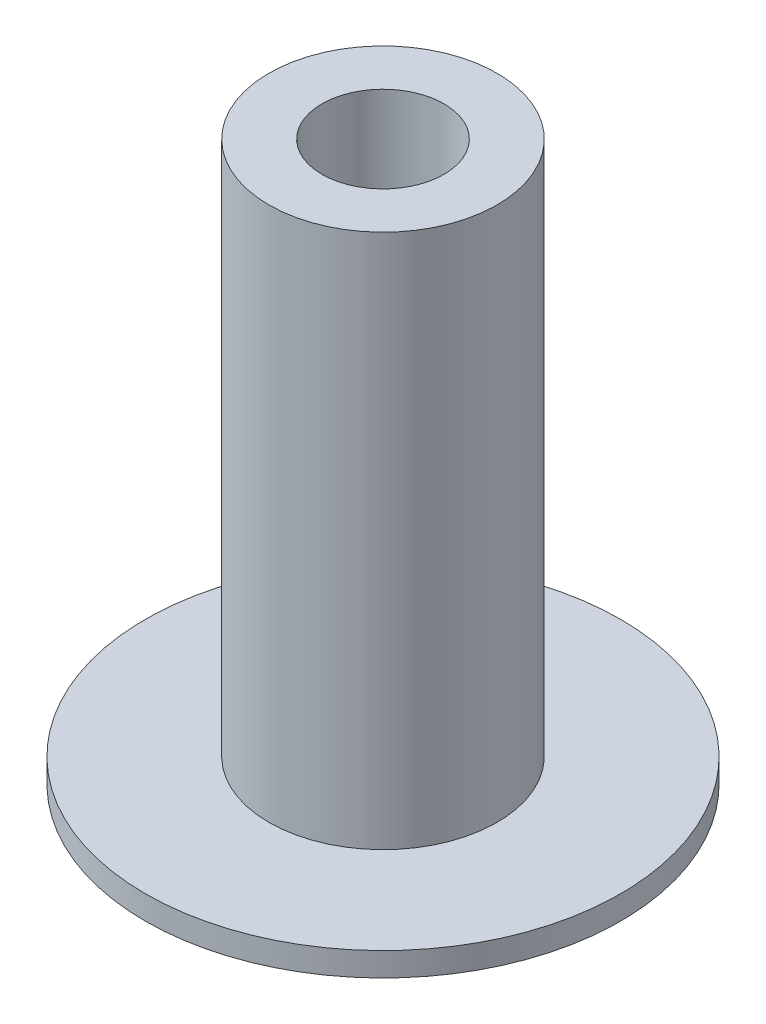
from build123d import *

# Parameters (mm, degrees)
SKETCH1_R                = 12.7
BOSS_EXTRUDE1_DEPTH      = 1.27
SKETCH2_R                = 6.096
BOSS_EXTRUDE2_DEPTH      = 28.575
F_5_16_18_TAPPED_HOLE1_D = 6.5278


with BuildPart() as part:
    # Sketch1 → Boss-Extrude1 (new body)
    with BuildSketch(Plane(origin=(0, 0, 0), x_dir=(1, 0, 0), z_dir=(0, 1, 0))):
        Circle(SKETCH1_R)
    extrude(amount=BOSS_EXTRUDE1_DEPTH)

    # Sketch2 → Boss-Extrude2 (add)
    with BuildSketch(Plane(origin=(0, 1.27, 0), x_dir=(1, 0, 0), z_dir=(0, 1, 0))):
        Circle(SKETCH2_R)
    extrude(amount=BOSS_EXTRUDE2_DEPTH)

    # 5/16-18 Tapped Hole1 (through all)
    with Locations(Plane(origin=(0, 29.845, 0), x_dir=(1, 0, 0), z_dir=(0, 1, 0))):
        with Locations((0, 0)):
            Hole(F_5_16_18_TAPPED_HOLE1_D / 2)


solid = part.part
